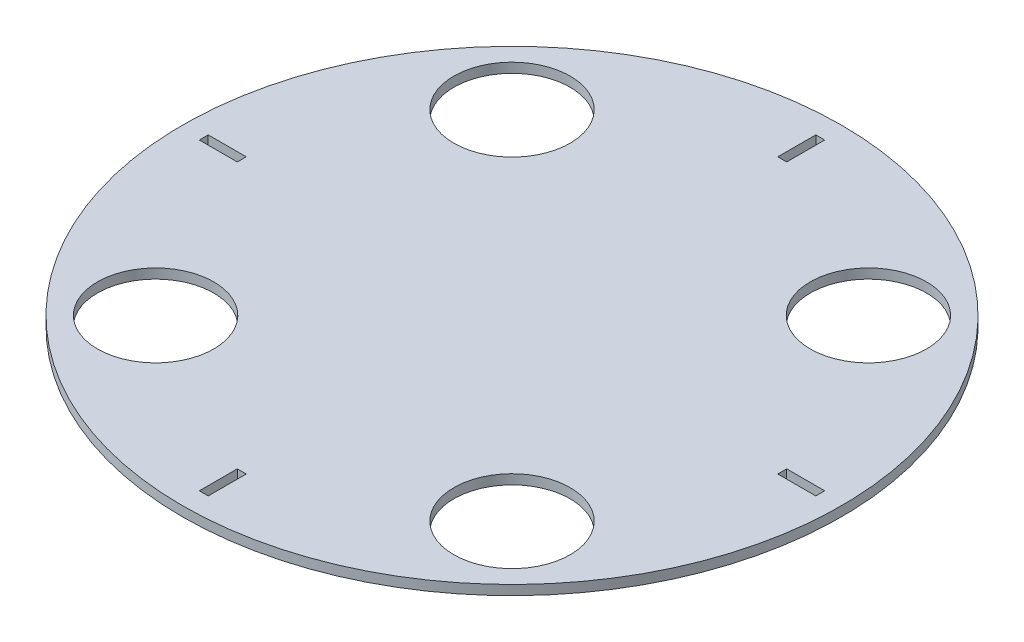
from build123d import *

# Parameters (mm, degrees)
SKETCH1_R           = 107.95
SKETCH1_R_2         = 19.05
SKETCH1_W           = 2.921
SKETCH1_H           = 12.446
SKETCH1_W_2         = 12.446
SKETCH1_H_2         = 2.921
BOSS_EXTRUDE1_DEPTH = 3.175


with BuildPart() as part:
    # Sketch1 → Boss-Extrude1 (new body)
    with BuildSketch(Plane(origin=(0, 0, 0), x_dir=(1, 0, 0), z_dir=(0, 1, 0))):
        Circle(SKETCH1_R)
        with Locations((58.371664787, 58.371664787)):
            Circle(SKETCH1_R_2, mode=Mode.SUBTRACT)
        with Locations((58.371664787, -58.371664787)):
            Circle(SKETCH1_R_2, mode=Mode.SUBTRACT)
        with Locations((-58.371664787, -58.371664787)):
            Circle(SKETCH1_R_2, mode=Mode.SUBTRACT)
        with Locations((-58.371664787, 58.371664787)):
            Circle(SKETCH1_R_2, mode=Mode.SUBTRACT)
        with Locations((0, -94.742)):
            Rectangle(SKETCH1_W, SKETCH1_H, mode=Mode.SUBTRACT)
        with Locations((94.742, 0)):
            Rectangle(SKETCH1_W_2, SKETCH1_H_2, mode=Mode.SUBTRACT)
        with Locations((-94.742, 0)):
            Rectangle(SKETCH1_W_2, SKETCH1_H_2, mode=Mode.SUBTRACT)
        with Locations((0, 94.742)):
            Rectangle(SKETCH1_W, SKETCH1_H, mode=Mode.SUBTRACT)
    extrude(amount=-BOSS_EXTRUDE1_DEPTH)


solid = part.part
